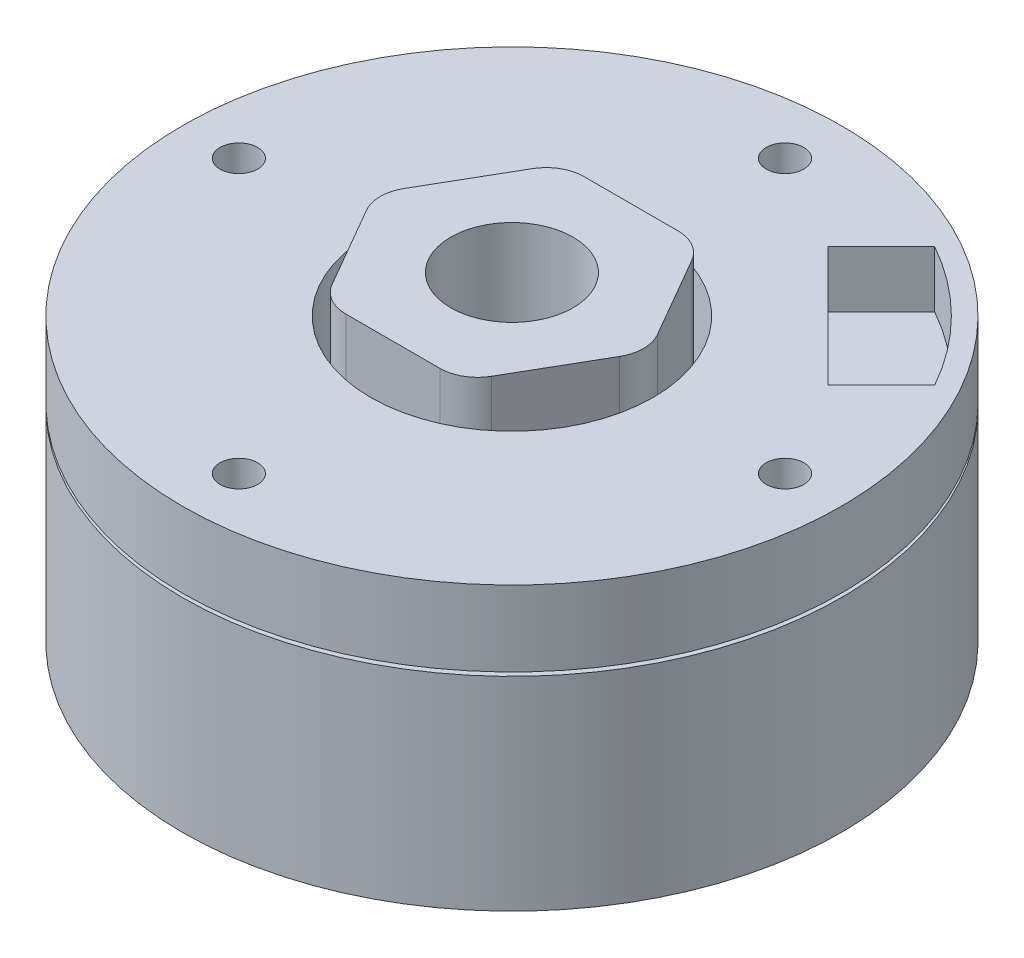
from build123d import *

# Parameters (mm, degrees)
SKETCH1_R           = 17.5
BOSS_EXTRUDE1_DEPTH = 15
BOSS_EXTRUDE2_DEPTH = 2
CUT_EXTRUDE1_REACH  = 19
SKETCH3_R           = 3.25
SKETCH4_R           = 1
CUT_EXTRUDE2_DEPTH  = 5
CIRPATTERN1_COUNT   = 4
SKETCH5_R           = 1
CUT_EXTRUDE3_DEPTH  = 2
CIRPATTERN2_COUNT   = 4
SKETCH6_R           = 7.5
CUT_EXTRUDE4_DEPTH  = 5
CUT_EXTRUDE6_START  = -4
SKETCH7_R           = 17.5
SKETCH7_R_2         = 12.5
CUT_EXTRUDE6_DEPTH  = 0.2
FILLET1_R           = 2
CUT_EXTRUDE7_DEPTH  = 3


with BuildPart() as part:
    # Sketch1 → Boss-Extrude1 (new body)
    with BuildSketch(Plane(origin=(0, 0, 0), x_dir=(1, 0, 0), z_dir=(0, 1, 0))):
        Circle(SKETCH1_R)
    extrude(amount=BOSS_EXTRUDE1_DEPTH)

    # Sketch2 → Boss-Extrude2 (add)
    with BuildSketch(Plane(origin=(0, 15, 0), x_dir=(1, 0, 0), z_dir=(0, 1, 0))):
        Polygon((7.3, 0), (3.65, 6.321985448), (-3.65, 6.321985448), (-7.3, 0), (-3.65, -6.321985448), (3.65, -6.321985448), align=None)
    extrude(amount=BOSS_EXTRUDE2_DEPTH)

    # Sketch3 → Cut-Extrude1 (cut, up to next)
    with BuildSketch(Plane.XZ, mode=Mode.PRIVATE) as cut_extrude1_sk1:
        Circle(SKETCH3_R)
    cut_extrude1_tool1 = extrude(cut_extrude1_sk1.sketch, amount=-CUT_EXTRUDE1_REACH, mode=Mode.PRIVATE) & part.part
    add(cut_extrude1_tool1.solids().sort_by_distance((0, 0, 0))[0], mode=Mode.SUBTRACT)

    # Sketch4 → Cut-Extrude2 (cut)
    with BuildSketch(Plane.XZ):
        with Locations((0, 9.5)):
            Circle(SKETCH4_R)
    cut_extrude2 = extrude(amount=-CUT_EXTRUDE2_DEPTH, mode=Mode.SUBTRACT)

    # CirPattern1: Cut-Extrude2 ×4 about axis
    cirpattern1_axis = Axis((0, 0, 0), (0, 1, 0))
    for i in range(1, CIRPATTERN1_COUNT):
        add(cut_extrude2.rotate(cirpattern1_axis, i * 360 / CIRPATTERN1_COUNT), mode=Mode.SUBTRACT)

    # Sketch5 → Cut-Extrude3 (cut)
    with BuildSketch(Plane(origin=(0, 15, 0), x_dir=(1, 0, 0), z_dir=(0, 1, 0))):
        with Locations((0, 14.5)):
            Circle(SKETCH5_R)
    cut_extrude3 = extrude(amount=-CUT_EXTRUDE3_DEPTH, mode=Mode.SUBTRACT)

    # CirPattern2: Cut-Extrude3 ×4 about axis
    cirpattern2_axis = Axis((0, 0, 0), (0, 1, 0))
    for i in range(1, CIRPATTERN2_COUNT):
        add(cut_extrude3.rotate(cirpattern2_axis, i * 360 / CIRPATTERN2_COUNT), mode=Mode.SUBTRACT)

    # Sketch6 → Cut-Extrude4 (cut)
    with BuildSketch(Plane(origin=(0, 15, 0), x_dir=(1, 0, 0), z_dir=(0, 1, 0))):
        Circle(SKETCH6_R)
        Polygon((7.3, 0), (3.65, 6.321985448), (-3.65, 6.321985448), (-7.3, 0), (-3.65, -6.321985448), (3.65, -6.321985448), align=None, mode=Mode.SUBTRACT)
    extrude(amount=-CUT_EXTRUDE4_DEPTH, mode=Mode.SUBTRACT)

    # Sketch7 → Cut-Extrude6 (cut)
    with BuildSketch(Plane(origin=(0, 15, 0), x_dir=(1, 0, 0), z_dir=(0, 1, 0)).offset(CUT_EXTRUDE6_START)):
        Circle(SKETCH7_R)
        Circle(SKETCH7_R_2, mode=Mode.SUBTRACT)
    extrude(amount=-CUT_EXTRUDE6_DEPTH, mode=Mode.SUBTRACT)

    # Fillet1
    fillet1_edges = [part.edges().sort_by_distance(p)[0] for p in [
        (-7.3, 13.5, 0),
        (-3.65, 13.5, 6.321985448),
        (3.65, 13.5, 6.321985448),
        (7.3, 13.5, 0),
        (3.65, 13.5, -6.321985448),
        (-3.65, 13.5, -6.321985448),
    ]]
    fillet(fillet1_edges, radius=FILLET1_R)

    # Sketch8 → Cut-Extrude7 (cut)
    with BuildSketch(Plane(origin=(0, 15, 0), x_dir=(1, 0, 0), z_dir=(0, 1, 0))):
        with BuildLine():
            Line((8.042991645, 14.406952676), (5.21456452, 11.578525551))
            Line((5.21456452, 11.578525551), (11.578525551, 5.21456452))
            Line((11.578525551, 5.21456452), (14.406952676, 8.042991645))
            ThreePointArc((14.406952676, 8.042991645), (11.66726189, 11.66726189), (8.042991645, 14.406952676))
        make_face()
    extrude(amount=-CUT_EXTRUDE7_DEPTH, mode=Mode.SUBTRACT)


solid = part.part
